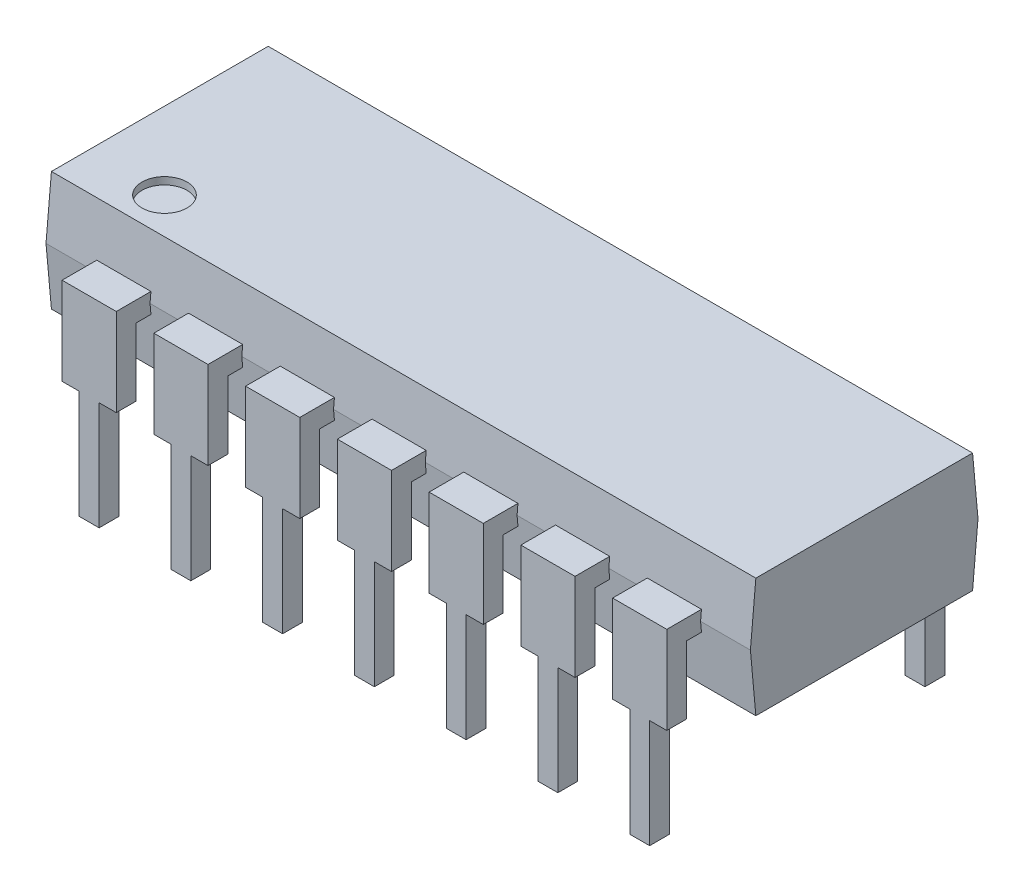
from build123d import *

# Parameters (mm, degrees)
BOSS_EXTRUDE1_DEPTH      = 19.5
SKETCH5_W                = 1.5
SKETCH5_H                = 1.085
BOSS_EXTRUDE2_DEPTH      = 0.275
SKETCH5_3_W              = 1.5
SKETCH5_3_H              = 0.55
BOSS_EXTRUDE4_DEPTH      = 2.15
SKETCH3_W                = 0.55
SKETCH3_H                = 0.55
BOSS_EXTRUDE5_DEPTH      = 3.5
LPATTERN1_COUNT          = 7
LPATTERN1_PITCH          = 2.54
MIRROR3_COPY_1_SKETCH_W  = 1.5
MIRROR3_COPY_1_SKETCH_H  = 1.085
MIRROR3_COPY_1_DEPTH     = 0.275
MIRROR3_COPY_2_SKETCH_W  = 1.5
MIRROR3_COPY_2_SKETCH_H  = 1.085
MIRROR3_COPY_2_DEPTH     = 0.275
MIRROR3_COPY_3_SKETCH_W  = 1.5
MIRROR3_COPY_3_SKETCH_H  = 1.085
MIRROR3_COPY_3_DEPTH     = 0.275
MIRROR3_COPY_4_SKETCH_W  = 1.5
MIRROR3_COPY_4_SKETCH_H  = 1.085
MIRROR3_COPY_4_DEPTH     = 0.275
MIRROR3_COPY_5_SKETCH_W  = 1.5
MIRROR3_COPY_5_SKETCH_H  = 1.085
MIRROR3_COPY_5_DEPTH     = 0.275
MIRROR3_COPY_6_SKETCH_W  = 1.5
MIRROR3_COPY_6_SKETCH_H  = 1.085
MIRROR3_COPY_6_DEPTH     = 0.275
MIRROR3_COPY_7_SKETCH_W  = 1.5
MIRROR3_COPY_7_SKETCH_H  = 0.55
MIRROR3_COPY_7_DEPTH     = 2.15
MIRROR3_COPY_8_SKETCH_W  = 1.5
MIRROR3_COPY_8_SKETCH_H  = 0.55
MIRROR3_COPY_8_DEPTH     = 2.15
MIRROR3_COPY_9_SKETCH_W  = 1.5
MIRROR3_COPY_9_SKETCH_H  = 0.55
MIRROR3_COPY_9_DEPTH     = 2.15
MIRROR3_COPY_10_SKETCH_W = 1.5
MIRROR3_COPY_10_SKETCH_H = 0.55
MIRROR3_COPY_10_DEPTH    = 2.15
MIRROR3_COPY_11_SKETCH_W = 1.5
MIRROR3_COPY_11_SKETCH_H = 0.55
MIRROR3_COPY_11_DEPTH    = 2.15
MIRROR3_COPY_12_SKETCH_W = 1.5
MIRROR3_COPY_12_SKETCH_H = 0.55
MIRROR3_COPY_12_DEPTH    = 2.15
MIRROR3_COPY_13_SKETCH_W = 0.55
MIRROR3_COPY_13_SKETCH_H = 0.55
MIRROR3_COPY_13_DEPTH    = 3.5
MIRROR3_COPY_14_SKETCH_W = 0.55
MIRROR3_COPY_14_SKETCH_H = 0.55
MIRROR3_COPY_14_DEPTH    = 3.5
MIRROR3_COPY_15_SKETCH_W = 0.55
MIRROR3_COPY_15_SKETCH_H = 0.55
MIRROR3_COPY_15_DEPTH    = 3.5
MIRROR3_COPY_16_SKETCH_W = 0.55
MIRROR3_COPY_16_SKETCH_H = 0.55
MIRROR3_COPY_16_DEPTH    = 3.5
MIRROR3_COPY_17_SKETCH_W = 0.55
MIRROR3_COPY_17_SKETCH_H = 0.55
MIRROR3_COPY_17_DEPTH    = 3.5
MIRROR3_COPY_18_SKETCH_W = 0.55
MIRROR3_COPY_18_SKETCH_H = 0.55
MIRROR3_COPY_18_DEPTH    = 3.5
SKETCH6_R                = 0.623672025
CUT_EXTRUDE1_DEPTH       = 0.2


with BuildPart() as part:
    # Sketch2 → Boss-Extrude1 (new body)
    with BuildSketch(Plane(origin=(0, 0, 0), x_dir=(0, 0, -1), z_dir=(1, 0, 0))):
        Polygon((0, 0), (0, 3.3), (-3, 3.3), (-3.15, 1.65), (-3, 0), align=None)
    boss_extrude1 = extrude(amount=BOSS_EXTRUDE1_DEPTH)

    # Mirror2: Boss-Extrude1 across plane
    add(boss_extrude1.mirror(Plane.XY))


with BuildPart() as body_2:
    # Sketch5 → Boss-Extrude2 (new, symmetric)
    with BuildSketch(Plane(origin=(0, 1.65, 0), x_dir=(1, 0, 0), z_dir=(0, 1, 0))):
        with Locations((2.13, -3.5425)):
            Rectangle(SKETCH5_W, SKETCH5_H)
    boss_extrude2 = extrude(amount=BOSS_EXTRUDE2_DEPTH, both=True)

    # Sketch5_3 → Boss-Extrude4 (add)
    with BuildSketch(Plane(origin=(0, 1.65, 0), x_dir=(1, 0, 0), z_dir=(0, 1, 0))):
        with Locations((2.13, -3.81)):
            Rectangle(SKETCH5_3_W, SKETCH5_3_H)
    boss_extrude4 = extrude(amount=-BOSS_EXTRUDE4_DEPTH)

    # Sketch3 → Boss-Extrude5 (add)
    with BuildSketch(Plane(origin=(0, 0, 0), x_dir=(1, 0, 0), z_dir=(0, 1, 0))):
        with Locations((2.13, -3.81)):
            Rectangle(SKETCH3_W, SKETCH3_H)
    boss_extrude5 = extrude(amount=-BOSS_EXTRUDE5_DEPTH)


with BuildPart() as lpattern1_1:
    # LPattern1: Boss-Extrude2, Boss-Extrude4, Boss-Extrude5 ×7
    with Locations(*[(i * LPATTERN1_PITCH, 0, 0) for i in range(1, LPATTERN1_COUNT)]):
        add(boss_extrude2)
        add(boss_extrude4)
        add(boss_extrude5)


with BuildPart() as part_1:
    add(part.part)

    # Mirror3: Boss-Extrude2, Boss-Extrude4, Boss-Extrude5 across plane
    add(boss_extrude2.mirror(Plane.XY))
    add(boss_extrude4.mirror(Plane.XY))
    add(boss_extrude5.mirror(Plane.XY))

    # Mirror3 copy 1 sketch → Mirror3 copy 1 (add, symmetric)
    with BuildSketch(Plane(origin=(2.54, 1.65, 0), x_dir=(1, 0, 0), z_dir=(0, 1, 0))):
        with Locations((2.13, 3.5425)):
            Rectangle(MIRROR3_COPY_1_SKETCH_W, MIRROR3_COPY_1_SKETCH_H)
    extrude(amount=MIRROR3_COPY_1_DEPTH, both=True)

    # Mirror3 copy 2 sketch → Mirror3 copy 2 (add, symmetric)
    with BuildSketch(Plane(origin=(5.08, 1.65, 0), x_dir=(1, 0, 0), z_dir=(0, 1, 0))):
        with Locations((2.13, 3.5425)):
            Rectangle(MIRROR3_COPY_2_SKETCH_W, MIRROR3_COPY_2_SKETCH_H)
    extrude(amount=MIRROR3_COPY_2_DEPTH, both=True)

    # Mirror3 copy 3 sketch → Mirror3 copy 3 (add, symmetric)
    with BuildSketch(Plane(origin=(7.62, 1.65, 0), x_dir=(1, 0, 0), z_dir=(0, 1, 0))):
        with Locations((2.13, 3.5425)):
            Rectangle(MIRROR3_COPY_3_SKETCH_W, MIRROR3_COPY_3_SKETCH_H)
    extrude(amount=MIRROR3_COPY_3_DEPTH, both=True)

    # Mirror3 copy 4 sketch → Mirror3 copy 4 (add, symmetric)
    with BuildSketch(Plane(origin=(10.16, 1.65, 0), x_dir=(1, 0, 0), z_dir=(0, 1, 0))):
        with Locations((2.13, 3.5425)):
            Rectangle(MIRROR3_COPY_4_SKETCH_W, MIRROR3_COPY_4_SKETCH_H)
    extrude(amount=MIRROR3_COPY_4_DEPTH, both=True)

    # Mirror3 copy 5 sketch → Mirror3 copy 5 (add, symmetric)
    with BuildSketch(Plane(origin=(12.7, 1.65, 0), x_dir=(1, 0, 0), z_dir=(0, 1, 0))):
        with Locations((2.13, 3.5425)):
            Rectangle(MIRROR3_COPY_5_SKETCH_W, MIRROR3_COPY_5_SKETCH_H)
    extrude(amount=MIRROR3_COPY_5_DEPTH, both=True)

    # Mirror3 copy 6 sketch → Mirror3 copy 6 (add, symmetric)
    with BuildSketch(Plane(origin=(15.24, 1.65, 0), x_dir=(1, 0, 0), z_dir=(0, 1, 0))):
        with Locations((2.13, 3.5425)):
            Rectangle(MIRROR3_COPY_6_SKETCH_W, MIRROR3_COPY_6_SKETCH_H)
    extrude(amount=MIRROR3_COPY_6_DEPTH, both=True)

    # Mirror3 copy 7 sketch → Mirror3 copy 7 (add)
    with BuildSketch(Plane(origin=(2.54, 1.65, 0), x_dir=(1, 0, 0), z_dir=(0, 1, 0))):
        with Locations((2.13, 3.81)):
            Rectangle(MIRROR3_COPY_7_SKETCH_W, MIRROR3_COPY_7_SKETCH_H)
    extrude(amount=-MIRROR3_COPY_7_DEPTH)

    # Mirror3 copy 8 sketch → Mirror3 copy 8 (add)
    with BuildSketch(Plane(origin=(5.08, 1.65, 0), x_dir=(1, 0, 0), z_dir=(0, 1, 0))):
        with Locations((2.13, 3.81)):
            Rectangle(MIRROR3_COPY_8_SKETCH_W, MIRROR3_COPY_8_SKETCH_H)
    extrude(amount=-MIRROR3_COPY_8_DEPTH)

    # Mirror3 copy 9 sketch → Mirror3 copy 9 (add)
    with BuildSketch(Plane(origin=(7.62, 1.65, 0), x_dir=(1, 0, 0), z_dir=(0, 1, 0))):
        with Locations((2.13, 3.81)):
            Rectangle(MIRROR3_COPY_9_SKETCH_W, MIRROR3_COPY_9_SKETCH_H)
    extrude(amount=-MIRROR3_COPY_9_DEPTH)

    # Mirror3 copy 10 sketch → Mirror3 copy 10 (add)
    with BuildSketch(Plane(origin=(10.16, 1.65, 0), x_dir=(1, 0, 0), z_dir=(0, 1, 0))):
        with Locations((2.13, 3.81)):
            Rectangle(MIRROR3_COPY_10_SKETCH_W, MIRROR3_COPY_10_SKETCH_H)
    extrude(amount=-MIRROR3_COPY_10_DEPTH)

    # Mirror3 copy 11 sketch → Mirror3 copy 11 (add)
    with BuildSketch(Plane(origin=(12.7, 1.65, 0), x_dir=(1, 0, 0), z_dir=(0, 1, 0))):
        with Locations((2.13, 3.81)):
            Rectangle(MIRROR3_COPY_11_SKETCH_W, MIRROR3_COPY_11_SKETCH_H)
    extrude(amount=-MIRROR3_COPY_11_DEPTH)

    # Mirror3 copy 12 sketch → Mirror3 copy 12 (add)
    with BuildSketch(Plane(origin=(15.24, 1.65, 0), x_dir=(1, 0, 0), z_dir=(0, 1, 0))):
        with Locations((2.13, 3.81)):
            Rectangle(MIRROR3_COPY_12_SKETCH_W, MIRROR3_COPY_12_SKETCH_H)
    extrude(amount=-MIRROR3_COPY_12_DEPTH)

    # Mirror3 copy 13 sketch → Mirror3 copy 13 (add)
    with BuildSketch(Plane(origin=(2.54, 0, 0), x_dir=(1, 0, 0), z_dir=(0, 1, 0))):
        with Locations((2.13, 3.81)):
            Rectangle(MIRROR3_COPY_13_SKETCH_W, MIRROR3_COPY_13_SKETCH_H)
    extrude(amount=-MIRROR3_COPY_13_DEPTH)

    # Mirror3 copy 14 sketch → Mirror3 copy 14 (add)
    with BuildSketch(Plane(origin=(5.08, 0, 0), x_dir=(1, 0, 0), z_dir=(0, 1, 0))):
        with Locations((2.13, 3.81)):
            Rectangle(MIRROR3_COPY_14_SKETCH_W, MIRROR3_COPY_14_SKETCH_H)
    extrude(amount=-MIRROR3_COPY_14_DEPTH)

    # Mirror3 copy 15 sketch → Mirror3 copy 15 (add)
    with BuildSketch(Plane(origin=(7.62, 0, 0), x_dir=(1, 0, 0), z_dir=(0, 1, 0))):
        with Locations((2.13, 3.81)):
            Rectangle(MIRROR3_COPY_15_SKETCH_W, MIRROR3_COPY_15_SKETCH_H)
    extrude(amount=-MIRROR3_COPY_15_DEPTH)

    # Mirror3 copy 16 sketch → Mirror3 copy 16 (add)
    with BuildSketch(Plane(origin=(10.16, 0, 0), x_dir=(1, 0, 0), z_dir=(0, 1, 0))):
        with Locations((2.13, 3.81)):
            Rectangle(MIRROR3_COPY_16_SKETCH_W, MIRROR3_COPY_16_SKETCH_H)
    extrude(amount=-MIRROR3_COPY_16_DEPTH)

    # Mirror3 copy 17 sketch → Mirror3 copy 17 (add)
    with BuildSketch(Plane(origin=(12.7, 0, 0), x_dir=(1, 0, 0), z_dir=(0, 1, 0))):
        with Locations((2.13, 3.81)):
            Rectangle(MIRROR3_COPY_17_SKETCH_W, MIRROR3_COPY_17_SKETCH_H)
    extrude(amount=-MIRROR3_COPY_17_DEPTH)

    # Mirror3 copy 18 sketch → Mirror3 copy 18 (add)
    with BuildSketch(Plane(origin=(15.24, 0, 0), x_dir=(1, 0, 0), z_dir=(0, 1, 0))):
        with Locations((2.13, 3.81)):
            Rectangle(MIRROR3_COPY_18_SKETCH_W, MIRROR3_COPY_18_SKETCH_H)
    extrude(amount=-MIRROR3_COPY_18_DEPTH)

    # Sketch6 → Cut-Extrude1 (cut)
    with BuildSketch(Plane(origin=(0, 3.3, 0), x_dir=(1, 0, 0), z_dir=(0, 1, 0))):
        with Locations((2.13, -2)):
            Circle(SKETCH6_R)
    extrude(amount=-CUT_EXTRUDE1_DEPTH, mode=Mode.SUBTRACT)


solid = Compound([body_2.part, lpattern1_1.part, part_1.part])
